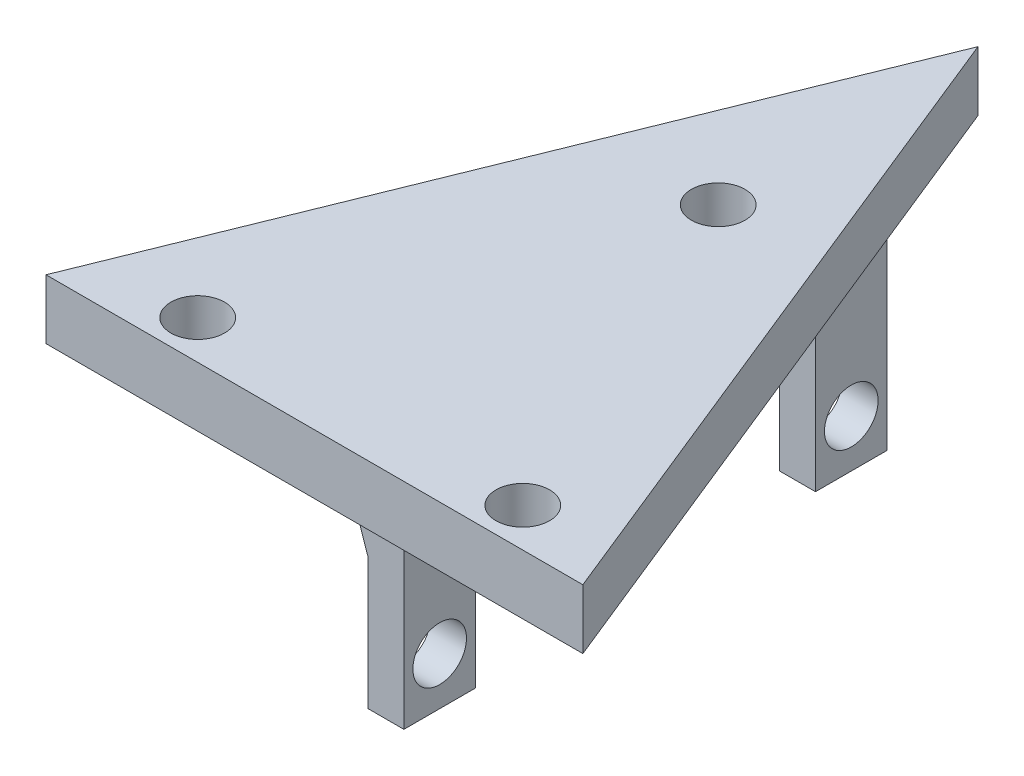
from build123d import *

# Parameters (mm, degrees)
BOSS_EXTRUDE1_DEPTH       = 5
F_8_CLEARANCE_HOLE1_D     = 4.4958
F_8_CLEARANCE_HOLE1_DEPTH = 17
F_8_CLEARANCE_HOLE1_TIP   = 1.350674586
SKETCH3_W                 = 3
SKETCH3_H                 = 6
BOSS_EXTRUDE2_DEPTH       = 18
RIB2_REACH                = 59.744
SKETCH17_WALL_W           = 124.92066757
SKETCH17_WALL_H           = 6
RIB3_REACH                = 59.054
SKETCH18_WALL_W           = 123.798893364
SKETCH18_WALL_H           = 6
F_8_CLEARANCE_HOLE2_D     = 4.4958
F_8_CLEARANCE_HOLE2_DEPTH = 17
F_8_CLEARANCE_HOLE2_TIP   = 1.350674586


with BuildPart() as part:
    # Sketch1 → Boss-Extrude1 (new body)
    with BuildSketch(Plane(origin=(0, 0, 0), x_dir=(1, 0, 0), z_dir=(0, 1, 0))):
        Polygon((-14.338976611, 0), (30.661023389, 0), (8.161023389, 55.621488653), align=None)
    extrude(amount=BOSS_EXTRUDE1_DEPTH)

    # #8 Clearance Hole1
    with Locations(Plane(origin=(22.377803879, 0, -3.25), x_dir=(0, 0, -1), z_dir=(0, -1, 0))):
        with Locations((0, 0), (0, -27.25), (30.001031232, -13.625)):
            Hole(F_8_CLEARANCE_HOLE1_D / 2, depth=F_8_CLEARANCE_HOLE1_DEPTH)
            with Locations((0, 0, -(F_8_CLEARANCE_HOLE1_DEPTH + F_8_CLEARANCE_HOLE1_TIP / 2))):  # 118° drill point
                Cone(0, F_8_CLEARANCE_HOLE1_D / 2, F_8_CLEARANCE_HOLE1_TIP, mode=Mode.SUBTRACT)

    # Sketch3 → Boss-Extrude2 (add)
    with BuildSketch(Plane(origin=(0, 0, 0), x_dir=(-1, 0, 0), z_dir=(0, -1, 0))):
        with Locations((-9.161023389, 42.5)):
            Rectangle(SKETCH3_W, SKETCH3_H)
        with Locations((-9.161023389, 8)):
            Rectangle(SKETCH3_W, SKETCH3_H)
    extrude(amount=BOSS_EXTRUDE2_DEPTH)

    # Sketch17 wall → Rib2 (add, up to next)
    with BuildSketch(Plane(origin=(6.411023389, -3.5, -45.5), x_dir=(-0.336336396998, 0.941741911595, 0), z_dir=(0.941741911595, 0.336336396998, 0)), mode=Mode.PRIVATE) as rib2_sk1:
        with Locations((0, 3)):
            Rectangle(SKETCH17_WALL_W, SKETCH17_WALL_H)
    rib2_tool1 = extrude(rib2_sk1.sketch, amount=RIB2_REACH, mode=Mode.PRIVATE) - part.part
    add(rib2_tool1.solids().sort_by_distance((6.411023389, -3.5, -45.5))[0])

    # Sketch18 wall → Rib3 (add, up to next)
    with BuildSketch(Plane(origin=(6.411023389, -3.36354082, -11), x_dir=(-0.32507212999, 0.945689225012, 0), z_dir=(0.945689225012, 0.32507212999, 0)), mode=Mode.PRIVATE) as rib3_sk1:
        with Locations((0, 3)):
            Rectangle(SKETCH18_WALL_W, SKETCH18_WALL_H)
    rib3_tool1 = extrude(rib3_sk1.sketch, amount=RIB3_REACH, mode=Mode.PRIVATE) - part.part
    add(rib3_tool1.solids().sort_by_distance((6.411023389, -3.36354082, -11))[0])

    # #8 Clearance Hole2
    with Locations(Plane(origin=(7.661023389, -14, -42.5), x_dir=(0, 0, -1), z_dir=(-1, 0, 0))):
        with Locations((0, 0), (-34.5, 0)):
            Hole(F_8_CLEARANCE_HOLE2_D / 2, depth=F_8_CLEARANCE_HOLE2_DEPTH)
            with Locations((0, 0, -(F_8_CLEARANCE_HOLE2_DEPTH + F_8_CLEARANCE_HOLE2_TIP / 2))):  # 118° drill point
                Cone(0, F_8_CLEARANCE_HOLE2_D / 2, F_8_CLEARANCE_HOLE2_TIP, mode=Mode.SUBTRACT)


solid = part.part
